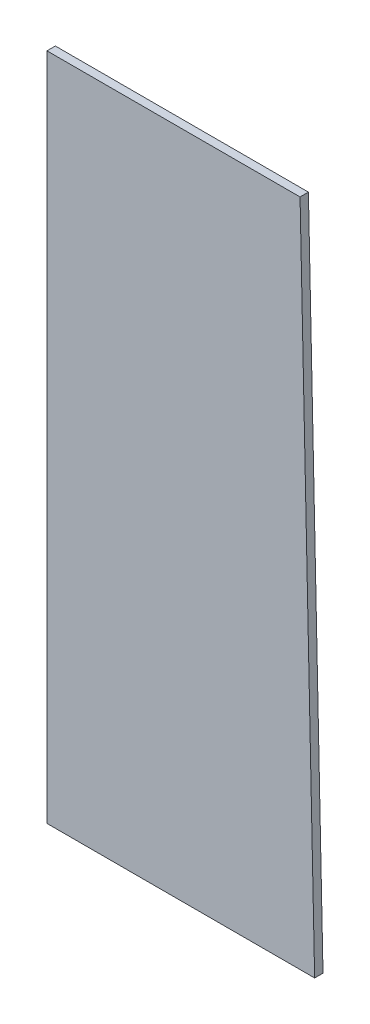
from build123d import *

# Parameters (mm, degrees)
THICKEN1_T2 = 50


with BuildPart() as body_1:
    # Sketch4 → Surface-Plane1: a flat surface bounded by the sketch
    with BuildSketch(Plane.XY, mode=Mode.PRIVATE) as surface_plane1_1_region:
        Polygon((0, 0), (0, 4000), (1512.79175792, 4000), (1600, 0), align=None)
    surface_plane1_1 = surface_plane1_1_region.sketch.faces()[0]
    add(Solid.thicken(surface_plane1_1, -THICKEN1_T2))


solid = body_1.part
